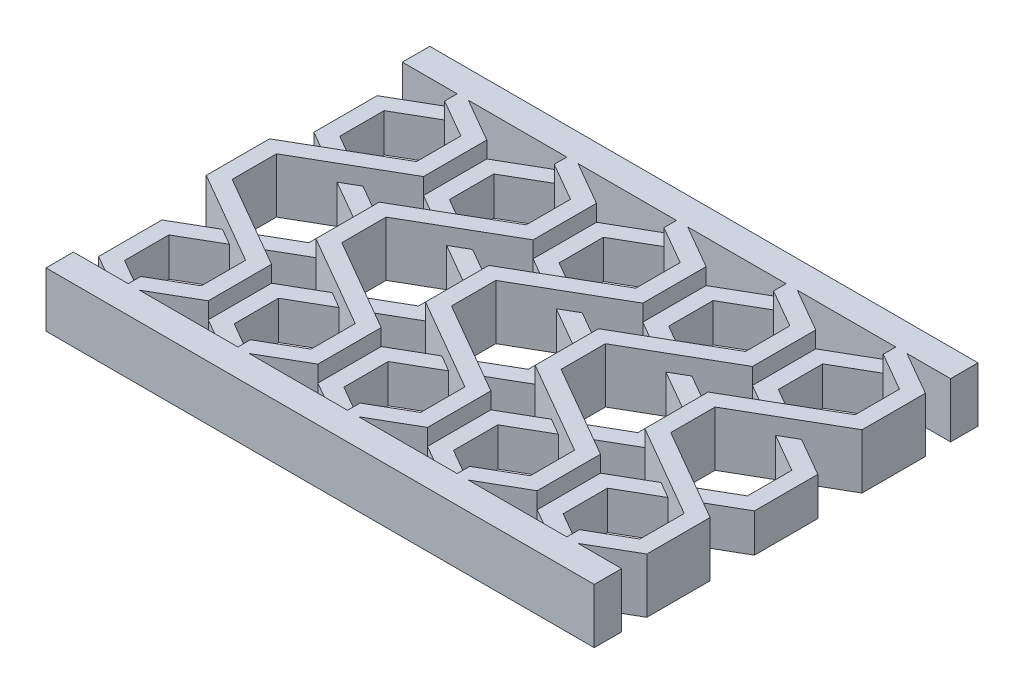
from build123d import *

# Parameters (mm, degrees)
BOSS_EXTRUDE4_DEPTH = 10
BOSS_EXTRUDE5_DEPTH = 7


with BuildPart() as part:
    # Sketch1 → Boss-Extrude4 (new body)
    with BuildSketch(Plane(origin=(0, 0, 0), x_dir=(1, 0, 0), z_dir=(0, 1, 0))):
        Polygon((-50, 35), (-50, 30), (-40, 30), (-40, 27.712812921), (-33, 23.671361037), (-33, 15.588457268), (-50, 5.773502692), (-50, -5.773502692), (-33, -15.588457268), (-33, -23.671361037), (-40, -27.712812921), (-40, -30), (-50, -30), (-50, -35), (50, -35), (50, -30), (42.038475773, -30), (50, -25.403411844), (50, -13.856406461), (33, -4.041451884), (33, 4.041451884), (50, 13.856406461), (50, 25.403411844), (42.038475773, 30), (50, 30), (50, 35), align=None)
        Polygon((40, 30), (40, 27.712812921), (47, 23.671361037), (47, 15.588457268), (30, 5.773502692), (30, -5.773502692), (47, -15.588457268), (47, -23.671361037), (40, -27.712812921), (40, -30), (22.038475773, -30), (30, -25.403411844), (30, -13.856406461), (13, -4.041451884), (13, 4.041451884), (30, 13.856406461), (30, 25.403411844), (22.038475773, 30), align=None, mode=Mode.SUBTRACT)
        Polygon((20, 30), (20, 27.712812921), (27, 23.671361037), (27, 15.588457268), (10, 5.773502692), (10, -5.773502692), (27, -15.588457268), (27, -23.671361037), (20, -27.712812921), (20, -30), (2.038475773, -30), (10, -25.403411844), (10, -13.856406461), (-7, -4.041451884), (-7, 4.041451884), (10, 13.856406461), (10, 25.403411844), (2.038475773, 30), align=None, mode=Mode.SUBTRACT)
        Polygon((0, 30), (0, 27.712812921), (7, 23.671361037), (7, 15.588457268), (-10, 5.773502692), (-10, -5.773502692), (7, -15.588457268), (7, -23.671361037), (0, -27.712812921), (0, -30), (-17.961524227, -30), (-10, -25.403411844), (-10, -13.856406461), (-27, -4.041451884), (-27, 4.041451884), (-10, 13.856406461), (-10, 25.403411844), (-17.961524227, 30), align=None, mode=Mode.SUBTRACT)
        Polygon((-20, 30), (-20, 27.712812921), (-13, 23.671361037), (-13, 15.588457268), (-30, 5.773502692), (-30, -5.773502692), (-13, -15.588457268), (-13, -23.671361037), (-20, -27.712812921), (-20, -30), (-37.961524227, -30), (-30, -25.403411844), (-30, -13.856406461), (-47, -4.041451884), (-47, 4.041451884), (-30, 13.856406461), (-30, 25.403411844), (-37.961524227, 30), align=None, mode=Mode.SUBTRACT)
    extrude(amount=BOSS_EXTRUDE4_DEPTH)

    # Sketch1_7 → Boss-Extrude5 (add)
    with BuildSketch(Plane(origin=(0, 0, 0), x_dir=(1, 0, 0), z_dir=(0, 1, 0))):
        Polygon((-40, 30), (-42.038475773, 30), (-50, 25.403411844), (-50, 13.856406461), (-43, 9.814954576), (-40, 11.547005384), (-47, 15.588457268), (-47, 23.671361037), (-40, 27.712812921), align=None)
        Polygon((-20, 30), (-22.038475773, 30), (-30, 25.403411844), (-30, 13.856406461), (-23, 9.814954576), (-20, 11.547005384), (-27, 15.588457268), (-27, 23.671361037), (-20, 27.712812921), align=None)
        Polygon((-37, 9.814954576), (-40, 8.082903769), (-33, 4.041451884), (-33, -4.041451884), (-40, -8.082903769), (-37, -9.814954576), (-30, -5.773502692), (-30, 5.773502692), align=None)
        Polygon((-43, -9.814954576), (-50, -13.856406461), (-50, -25.403411844), (-42.038475773, -30), (-40, -30), (-40, -27.712812921), (-47, -23.671361037), (-47, -15.588457268), (-40, -11.547005384), align=None)
        Polygon((40, 27.712812921), (40, 30), (37.961524227, 30), (30, 25.403411844), (30, 13.856406461), (37, 9.814954576), (40, 11.547005384), (33, 15.588457268), (33, 23.671361037), align=None)
        Polygon((50, -5.773502692), (50, 5.773502692), (43, 9.814954576), (40, 8.082903769), (47, 4.041451884), (47, -4.041451884), (40, -8.082903769), (43, -9.814954576), align=None)
        Polygon((0, 30), (-2.038475773, 30), (-10, 25.403411844), (-10, 13.856406461), (-3, 9.814954576), (0, 11.547005384), (-7, 15.588457268), (-7, 23.671361037), (0, 27.712812921), align=None)
        Polygon((-17, 9.814954576), (-20, 8.082903769), (-13, 4.041451884), (-13, -4.041451884), (-20, -8.082903769), (-17, -9.814954576), (-10, -5.773502692), (-10, 5.773502692), align=None)
        Polygon((-23, -9.814954576), (-30, -13.856406461), (-30, -25.403411844), (-22.038475773, -30), (-20, -30), (-20, -27.712812921), (-27, -23.671361037), (-27, -15.588457268), (-20, -11.547005384), align=None)
        Polygon((20, 27.712812921), (20, 30), (17.961524227, 30), (10, 25.403411844), (10, 13.856406461), (17, 9.814954576), (20, 11.547005384), (13, 15.588457268), (13, 23.671361037), align=None)
        Polygon((30, 5.773502692), (23, 9.814954576), (20, 8.082903769), (27, 4.041451884), (27, -4.041451884), (20, -8.082903769), (23, -9.814954576), (30, -5.773502692), align=None)
        Polygon((33, -15.588457268), (40, -11.547005384), (37, -9.814954576), (30, -13.856406461), (30, -25.403411844), (37.961524227, -30), (40, -30), (40, -27.712812921), (33, -23.671361037), align=None)
        Polygon((3, 9.814954576), (0, 8.082903769), (7, 4.041451884), (7, -4.041451884), (0, -8.082903769), (3, -9.814954576), (10, -5.773502692), (10, 5.773502692), align=None)
        Polygon((-3, -9.814954576), (-10, -13.856406461), (-10, -25.403411844), (-2.038475773, -30), (0, -30), (0, -27.712812921), (-7, -23.671361037), (-7, -15.588457268), (0, -11.547005384), align=None)
        Polygon((20, -11.547005384), (17, -9.814954576), (10, -13.856406461), (10, -25.403411844), (17.961524227, -30), (20, -30), (20, -27.712812921), (13, -23.671361037), (13, -15.588457268), align=None)
    extrude(amount=BOSS_EXTRUDE5_DEPTH)


solid = part.part
